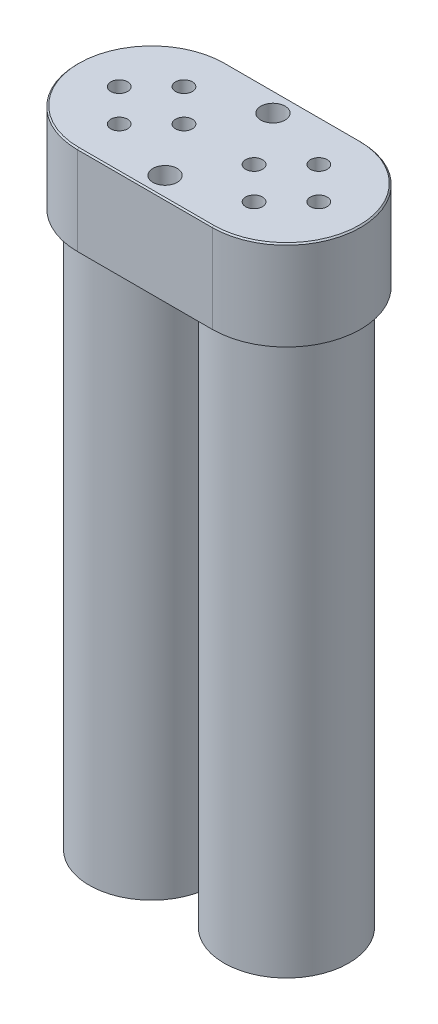
from build123d import *

# Parameters (mm, degrees)
BOSS_EXTRUDE1_DEPTH = 16.8656
CHAMFER1_SIZE       = 0.254
SKETCH2_R           = 11.7475
BOSS_EXTRUDE2_DEPTH = 104.521
SKETCH3_R           = 1.5875
CUT_EXTRUDE1_DEPTH  = 16.3576
SKETCH4_R           = 2.286
CUT_EXTRUDE2_DEPTH  = 122.3866


with BuildPart() as part:
    # Sketch1 → Boss-Extrude1 (new body)
    with BuildSketch(Plane(origin=(0, 0, 0), x_dir=(1, 0, 0), z_dir=(0, 1, 0))):
        with BuildLine():
            Line((0, 13.97), (25.4, 13.97))
            ThreePointArc((25.4, 13.97), (39.37, 0), (25.4, -13.97))
            Line((25.4, -13.97), (0, -13.97))
            ThreePointArc((0, -13.97), (-13.97, 0), (0, 13.97))
        make_face()
    extrude(amount=BOSS_EXTRUDE1_DEPTH)

    # Chamfer1
    chamfer1_edges = [part.edges().sort_by_distance(p)[0] for p in [
        (39.37, 16.8656, 0),
        (12.7, 16.8656, -13.97),
        (-13.97, 16.8656, 0),
        (12.7, 16.8656, 13.97),
    ]]
    chamfer(chamfer1_edges, length=CHAMFER1_SIZE)

    # Sketch2 → Boss-Extrude2 (add)
    with BuildSketch(Plane.XZ):
        Circle(SKETCH2_R)
        with Locations((25.4, 0)):
            Circle(SKETCH2_R)
    extrude(amount=BOSS_EXTRUDE2_DEPTH)

    # Sketch3 → Cut-Extrude1 (cut)
    with BuildSketch(Plane(origin=(0, 16.8656, 0), x_dir=(1, 0, 0), z_dir=(0, 1, 0))):
        with Locations((25.4, 6.096)):
            Circle(SKETCH3_R)
        with Locations((31.496, 0)):
            Circle(SKETCH3_R)
        with Locations((25.4, -6.096)):
            Circle(SKETCH3_R)
        with Locations((19.304, 0)):
            Circle(SKETCH3_R)
        with Locations((-6.096, 0)):
            Circle(SKETCH3_R)
        with Locations((6.096, 0)):
            Circle(SKETCH3_R)
        with Locations((0, -6.096)):
            Circle(SKETCH3_R)
        with Locations((0, 6.096)):
            Circle(SKETCH3_R)
    extrude(amount=-CUT_EXTRUDE1_DEPTH, mode=Mode.SUBTRACT)

    # Sketch4 → Cut-Extrude2 (cut, through all)
    with BuildSketch(Plane(origin=(0, 16.8656, 0), x_dir=(1, 0, 0), z_dir=(0, 1, 0))):
        with Locations((12.7, 10.16)):
            Circle(SKETCH4_R)
        with Locations((12.7, -10.16)):
            Circle(SKETCH4_R)
    extrude(amount=-CUT_EXTRUDE2_DEPTH, mode=Mode.SUBTRACT)


solid = part.part
